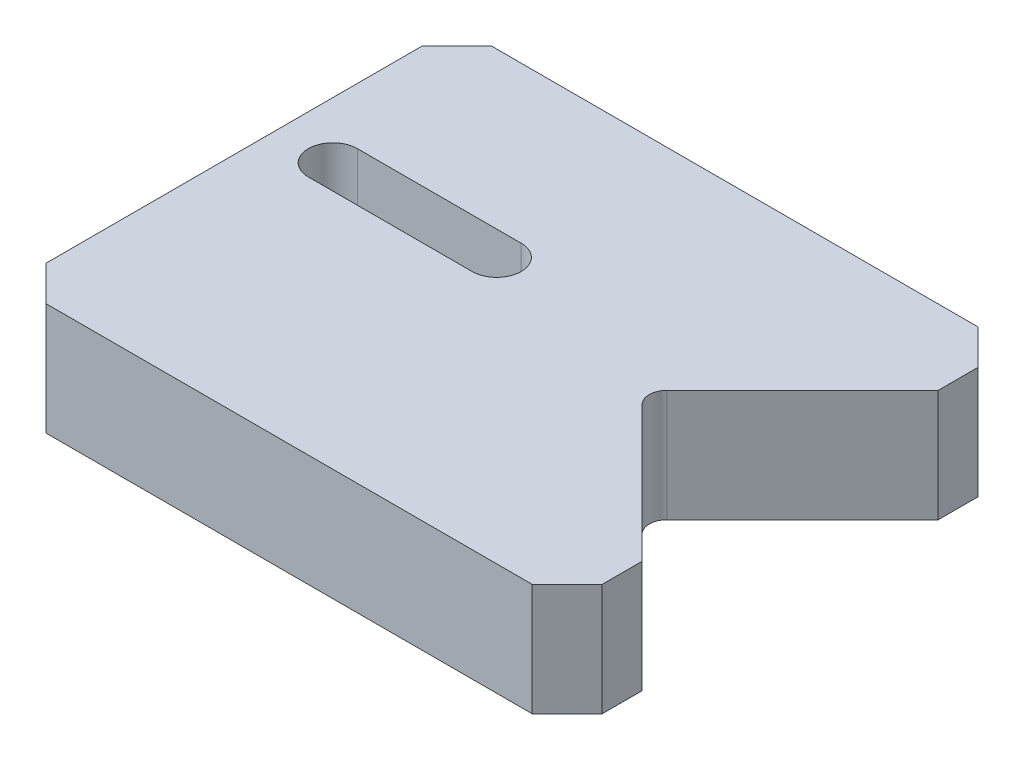
from build123d import *

# Parameters (mm, degrees)
RESSALTO_EXTRUS_O2_DEPTH = 12.8


with BuildPart() as part:
    # Esboço1 → Ressalto-extrusão2 (new body)
    with BuildSketch(Plane(origin=(0, 0, 0), x_dir=(1, 0, 0), z_dir=(0, 1, 0))):
        with BuildLine():
            Line((-27.75, 25.45), (27.75, 25.45))
            Line((27.75, 25.45), (31.75, 21.45))
            Line((31.75, 21.45), (31.75, 16.9))
            Line((31.75, 16.9), (16.264213562, 1.414213562))
            ThreePointArc((16.264213562, 1.414213562), (15.678427125, 0), (16.264213562, -1.414213562))
            Line((16.264213562, -1.414213562), (31.75, -16.9))
            Line((31.75, -16.9), (31.75, -21.45))
            Line((31.75, -21.45), (27.75, -25.45))
            Line((27.75, -25.45), (-27.75, -25.45))
            Line((-27.75, -25.45), (-31.75, -21.45))
            Line((-31.75, -21.45), (-31.75, 21.45))
            Line((-31.75, 21.45), (-27.75, 25.45))
        make_face()
        with BuildLine():
            Line((-25.3, 7.65), (-6.6, 7.65))
            ThreePointArc((-6.6, 7.65), (-3.8, 4.85), (-6.6, 2.05))
            Line((-6.6, 2.05), (-25.3, 2.05))
            ThreePointArc((-25.3, 2.05), (-28.1, 4.85), (-25.3, 7.65))
        make_face(mode=Mode.SUBTRACT)
    extrude(amount=RESSALTO_EXTRUS_O2_DEPTH)


solid = part.part
